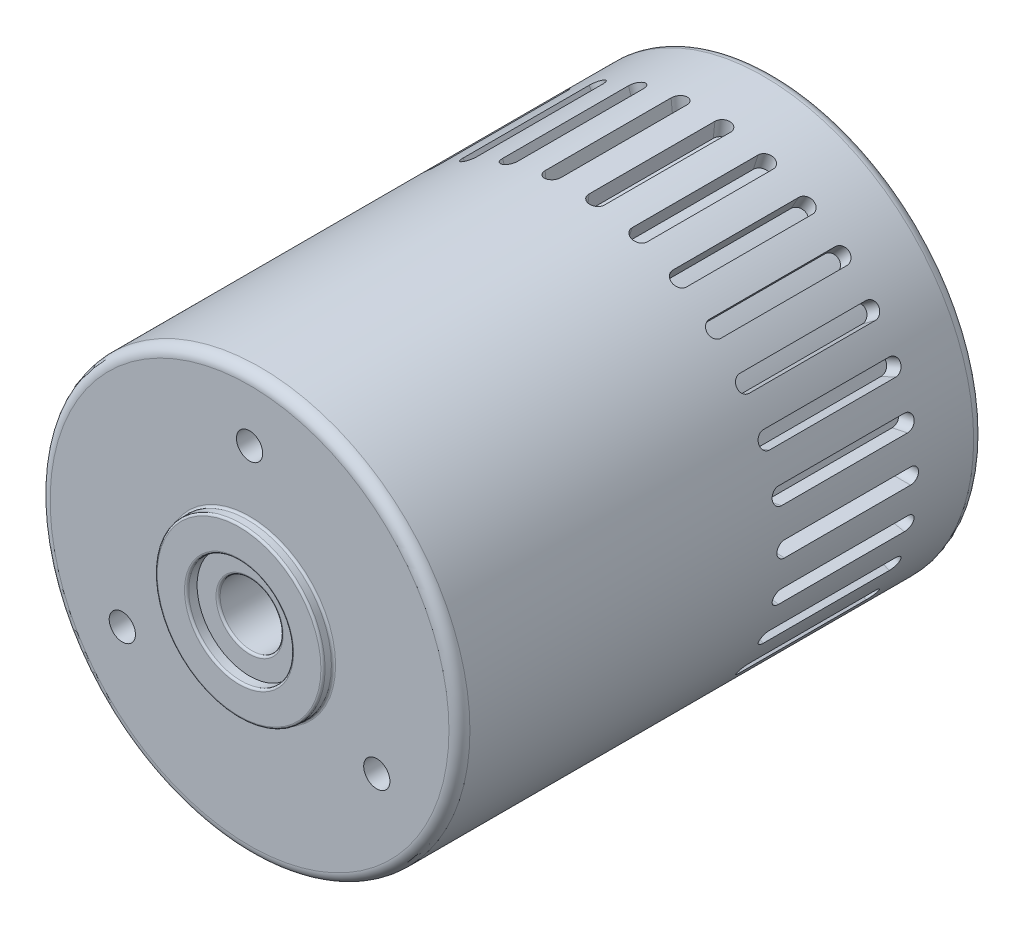
from build123d import *

# Parameters (mm, degrees)
SKETCH1_R               = 10
BOSS_EXTRUDE1_DEPTH     = 25
SKETCH2_R               = 4
SKETCH2_R_2             = 2.5
BOSS_EXTRUDE2_DEPTH     = 0.5
SKETCH3_R               = 1.5
BOSS_EXTRUDE3_DEPTH     = 0.5
CUT_EXTRUDE1_REACH      = 61.159
CUT_EXTRUDE1_END_RADIUS = 10
CUT_EXTRUDE1_START      = 30
CIRPATTERN1_COUNT       = 30
SKETCH5_R               = 1.5
CUT_EXTRUDE2_DEPTH      = 5
FILLET1_R               = 0.5
SKETCH6_R               = 0.625
CUT_EXTRUDE3_DEPTH      = 5
FILLET2_R               = 0.1


with BuildPart() as part:
    # Sketch1 → Boss-Extrude1 (new body)
    with BuildSketch(Plane.XY):
        Circle(SKETCH1_R)
    extrude(amount=-BOSS_EXTRUDE1_DEPTH)

    # Sketch2 → Boss-Extrude2 (add)
    with BuildSketch(Plane.XY):
        Circle(SKETCH2_R)
        Circle(SKETCH2_R_2, mode=Mode.SUBTRACT)
    extrude(amount=BOSS_EXTRUDE2_DEPTH)

    # Sketch3 → Boss-Extrude3 (add)
    with BuildSketch(Plane(origin=(0, 0, -25), x_dir=(-1, 0, 0), z_dir=(0, 0, -1))):
        Circle(SKETCH3_R)
    extrude(amount=BOSS_EXTRUDE3_DEPTH)

    # Cut-Extrude1: up to this cylinder (the profile starts outside it)
    cut_extrude1_end = Plane(origin=(-0.75, 0, -18.5), z_dir=(0, 0, 1)) * Cylinder(CUT_EXTRUDE1_END_RADIUS, 143.318, mode=Mode.PRIVATE)
    # Sketch4 → Cut-Extrude1 (cut, up to the surface)
    with BuildSketch(Plane(origin=(0, 0, 0), x_dir=(0, 0, -1), z_dir=(1, 0, 0)).offset(CUT_EXTRUDE1_START), mode=Mode.PRIVATE) as cut_extrude1_sk1:
        with BuildLine():
            Line((15.5, 0.375), (21.5, 0.375))
            ThreePointArc((21.5, 0.375), (21.875, 0), (21.5, -0.375))
            Line((21.5, -0.375), (15.5, -0.375))
            ThreePointArc((15.5, -0.375), (15.125, 0), (15.5, 0.375))
        make_face()
    cut_extrude1_tool1 = extrude(cut_extrude1_sk1.sketch, amount=-CUT_EXTRUDE1_REACH, mode=Mode.PRIVATE) - cut_extrude1_end
    cut_extrude1 = cut_extrude1_tool1.solids().sort_by_distance((30, 0, -18.5))[0]
    add(cut_extrude1, mode=Mode.SUBTRACT)

    # CirPattern1: Cut-Extrude1 ×30 about axis
    cirpattern1_axis = Axis((0, 0, 0), (0, 0, 1))
    for i in range(1, CIRPATTERN1_COUNT):
        add(cut_extrude1.rotate(cirpattern1_axis, i * 360 / CIRPATTERN1_COUNT), mode=Mode.SUBTRACT)

    # Sketch5 → Cut-Extrude2 (cut)
    with BuildSketch(Plane.XY):
        with Locations(Location((0, 0, 0), (0, 0, 180))):
            Circle(SKETCH5_R)
    extrude(amount=-CUT_EXTRUDE2_DEPTH, mode=Mode.SUBTRACT)

    # Fillet1
    fillet1_edges = [part.edges().sort_by_distance(p)[0] for p in [
        (-10, 0, 0),
        (-10, 0, -25),
    ]]
    fillet(fillet1_edges, radius=FILLET1_R)

    # Sketch6 → Cut-Extrude3 (cut)
    with BuildSketch(Plane.XY):
        with Locations((0, 7)):
            Circle(SKETCH6_R)
        with Locations((6.062177826, -3.5)):
            Circle(SKETCH6_R)
        with Locations((-6.062177826, -3.5)):
            Circle(SKETCH6_R)
    extrude(amount=-CUT_EXTRUDE3_DEPTH, mode=Mode.SUBTRACT)

    # Fillet2
    fillet2_edges = [part.edges().sort_by_distance(p)[0] for p in [
        (1.5, 0, -25),
        (1.5, 0, -25.5),
        (1.5, 0, 0),
        (-4, 0, 0.5),
        (-4, 0, 0),
        (-2.5, 0, 0.5),
    ]]
    fillet(fillet2_edges, radius=FILLET2_R)


solid = part.part
